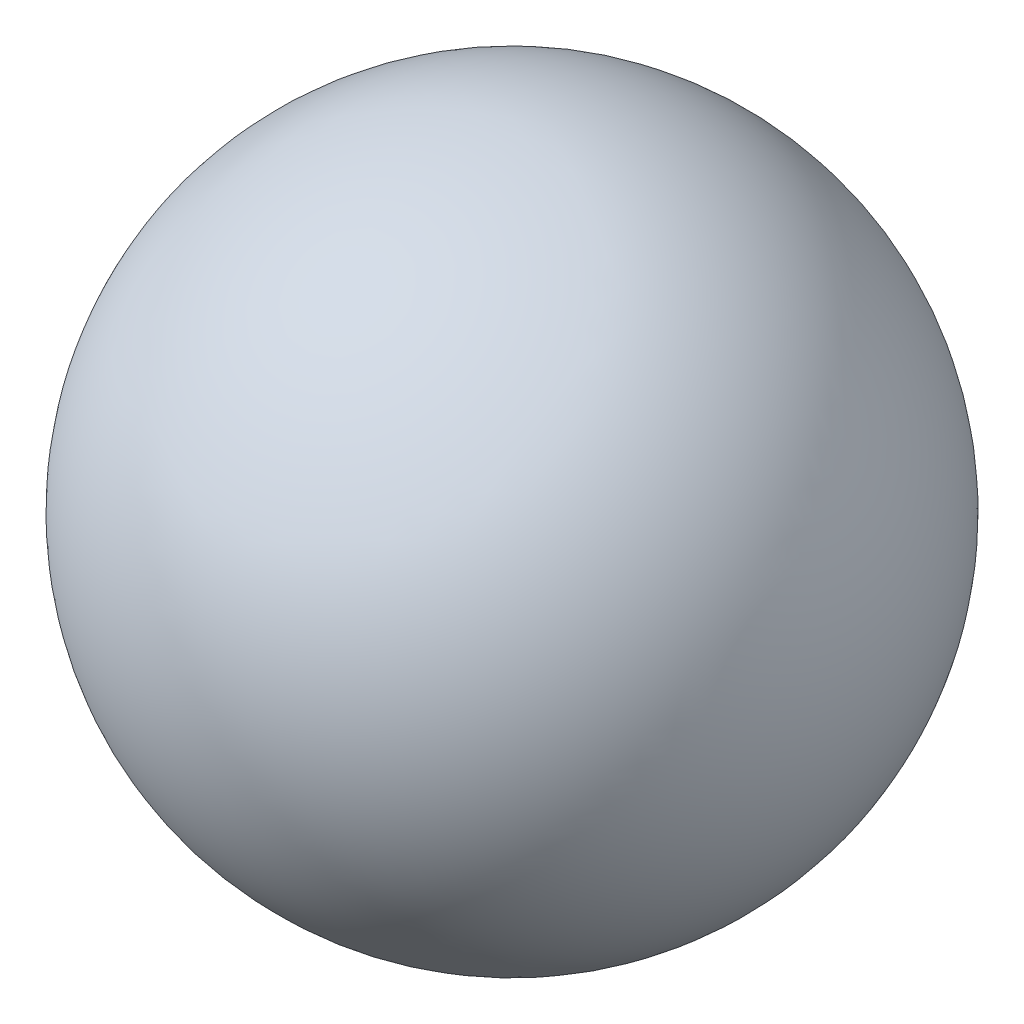
from build123d import *


with BuildPart() as part:
    # Sketch2 → Revolve1 (revolve)
    with BuildSketch(Plane(origin=(0, 0, 0), x_dir=(1, 0, 0), z_dir=(0, 1, 0))):
        with BuildLine():
            Line((-1.5, 0), (1.5, 0))
            ThreePointArc((1.5, 0), (0, 1.5), (-1.5, 0))
        make_face()
    revolve(axis=Axis((-1.5, 0, 0), (1, 0, 0)))


solid = part.part
